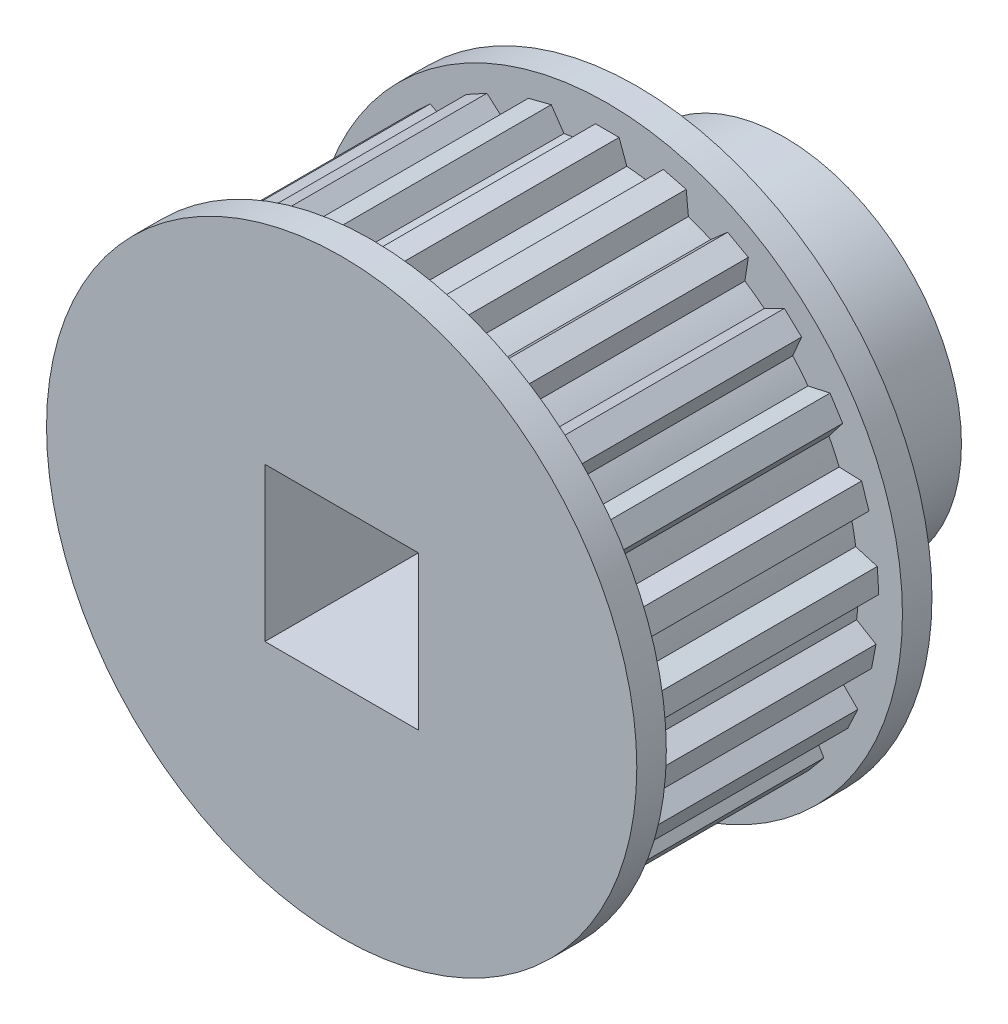
from build123d import *

# Parameters (mm, degrees)
BOSS_EXTRUDE1_DEPTH = 5
SKETCH2_R           = 10
BOSS_EXTRUDE2_DEPTH = 1
SKETCH4_R           = 6
BOSS_EXTRUDE3_DEPTH = 5
CUT_EXTRUDE1_REACH  = 17
SKETCH5_W           = 5.2
SKETCH5_H           = 5.2


with BuildPart() as part:
    # Sketch1 → Boss-Extrude1 (new body, symmetric)
    with BuildSketch(Plane.XY):
        with BuildLine():
            Line((-0.4, 9.191300234), (-0.660980834, 8.474261286))
            ThreePointArc((-0.660980834, 8.474261286), (-1.065332485, 8.432974961), (-1.467248177, 8.372406033))
            Line((-1.467248177, 8.372406033), (-1.898350154, 9.002014591))
            Line((-1.898350154, 9.002014591), (-2.673216683, 8.803062681))
            Line((-2.673216683, 8.803062681), (-2.747677989, 8.043647535))
            ThreePointArc((-2.747677989, 8.043647535), (-3.129058698, 7.90310013), (-3.503284589, 7.744481718))
            Line((-3.503284589, 7.744481718), (-4.077419986, 8.247099263))
            Line((-4.077419986, 8.247099263), (-4.77846533, 7.861696324))
            Line((-4.77846533, 7.861696324), (-4.66172843, 7.107621828))
            ThreePointArc((-4.66172843, 7.107621828), (-4.996174644, 6.876644452), (-5.319196746, 6.629943135))
            Line((-5.319196746, 6.629943135), (-6.000290524, 6.973988359))
            Line((-6.000290524, 6.973988359), (-6.583465426, 6.426350674))
            Line((-6.583465426, 6.426350674), (-6.282865329, 5.724998101))
            ThreePointArc((-6.282865329, 5.724998101), (-6.549362564, 5.418103913), (-6.80088421, 5.098820841))
            Line((-6.80088421, 5.098820841), (-7.546140742, 5.262676117))
            Line((-7.546140742, 5.262676117), (-7.974802178, 4.587213776))
            Line((-7.974802178, 4.587213776), (-7.509226693, 3.982651688))
            ThreePointArc((-7.509226693, 3.982651688), (-7.691029946, 3.619123978), (-7.855247106, 3.247320882))
            Line((-7.855247106, 3.247320882), (-8.617839183, 3.220690579))
            Line((-8.617839183, 3.220690579), (-8.865052779, 2.459845366))
            Line((-8.865052779, 2.459845366), (-8.263755727, 1.990060623))
            ThreePointArc((-8.263755727, 1.990060623), (-8.349441631, 1.592741174), (-8.416035937, 1.191779808))
            Line((-8.416035937, 1.191779808), (-9.148047095, 0.976337208))
            Line((-9.148047095, 0.976337208), (-9.198279511, 0.177915826))
            Line((-9.198279511, 0.177915826), (-8.499042597, -0.127573271))
            ThreePointArc((-8.499042597, -0.127573271), (-8.483227192, -0.533719416), (-8.448014278, -0.938645173))
            Line((-8.448014278, -0.938645173), (-9.103449564, -1.32936302))
            Line((-9.103449564, -1.32936302), (-8.953544512, -2.115192821))
            Line((-8.953544512, -2.115192821), (-8.200303363, -2.237191266))
            ThreePointArc((-8.200303363, -2.237191266), (-8.083980389, -2.626644452), (-7.949172812, -3.010091627))
            Line((-7.949172812, -3.010091627), (-8.486848816, -3.551534481))
            Line((-8.486848816, -3.551534481), (-8.146225383, -4.275396123))
            Line((-8.146225383, -4.275396123), (-7.38630891, -4.206238307))
            ThreePointArc((-7.38630891, -4.206238307), (-7.176787367, -4.554527757), (-6.950855584, -4.892402953))
            Line((-6.950855584, -4.892402953), (-7.336988145, -5.550549969))
            Line((-7.336988145, -5.550549969), (-6.827048953, -6.166960564))
            Line((-6.827048953, -6.166960564), (-6.108205503, -5.910991925))
            ThreePointArc((-6.108205503, -5.910991925), (-5.8186504, -6.196233333), (-5.515790536, -6.467306608))
            Line((-5.515790536, -6.467306608), (-5.726117525, -7.200803989))
            Line((-5.726117525, -7.200803989), (-5.078903929, -7.671032191))
            Line((-5.078903929, -7.671032191), (-4.44630108, -7.244336181))
            ThreePointArc((-4.44630108, -7.244336181), (-4.09490623, -7.44860678), (-3.734148082, -7.635845605))
            Line((-3.734148082, -7.635845605), (-3.755453882, -8.398605012))
            Line((-3.755453882, -8.398605012), (-3.011632693, -8.693104654))
            Line((-3.011632693, -8.693104654), (-2.505019208, -8.122492153))
            ThreePointArc((-2.505019208, -8.122492153), (-2.113864041, -8.23295687), (-1.717875372, -8.324596339))
            Line((-1.717875372, -8.324596339), (-1.54882126, -9.068690793))
            Line((-1.54882126, -9.068690793), (-0.755129499, -9.16895738))
            Line((-0.755129499, -9.16895738), (-0.406337766, -8.49028207))
            ThreePointArc((-0.406337766, -8.49028207), (0, -8.5), (0.406337766, -8.49028207))
            Line((0.406337766, -8.49028207), (0.755129499, -9.16895738))
            Line((0.755129499, -9.16895738), (1.54882126, -9.068690793))
            Line((1.54882126, -9.068690793), (1.717875372, -8.324596339))
            ThreePointArc((1.717875372, -8.324596339), (2.113864041, -8.23295687), (2.505019208, -8.122492153))
            Line((2.505019208, -8.122492153), (3.011632693, -8.693104654))
            Line((3.011632693, -8.693104654), (3.755453882, -8.398605012))
            Line((3.755453882, -8.398605012), (3.734148082, -7.635845605))
            ThreePointArc((3.734148082, -7.635845605), (4.09490623, -7.44860678), (4.44630108, -7.244336181))
            Line((4.44630108, -7.244336181), (5.078903929, -7.671032191))
            Line((5.078903929, -7.671032191), (5.726117525, -7.200803989))
            Line((5.726117525, -7.200803989), (5.515790536, -6.467306608))
            ThreePointArc((5.515790536, -6.467306608), (5.8186504, -6.196233333), (6.108205503, -5.910991925))
            Line((6.108205503, -5.910991925), (6.827048953, -6.166960564))
            Line((6.827048953, -6.166960564), (7.336988145, -5.550549969))
            Line((7.336988145, -5.550549969), (6.950855584, -4.892402953))
            ThreePointArc((6.950855584, -4.892402953), (7.176787367, -4.554527757), (7.38630891, -4.206238307))
            Line((7.38630891, -4.206238307), (8.146225383, -4.275396123))
            Line((8.146225383, -4.275396123), (8.486848816, -3.551534481))
            Line((8.486848816, -3.551534481), (7.949172812, -3.010091627))
            ThreePointArc((7.949172812, -3.010091627), (8.083980389, -2.626644452), (8.200303363, -2.237191266))
            Line((8.200303363, -2.237191266), (8.953544512, -2.115192821))
            Line((8.953544512, -2.115192821), (9.103449564, -1.32936302))
            Line((9.103449564, -1.32936302), (8.448014278, -0.938645173))
            ThreePointArc((8.448014278, -0.938645173), (8.483227192, -0.533719416), (8.499042597, -0.127573271))
            Line((8.499042597, -0.127573271), (9.198279511, 0.177915826))
            Line((9.198279511, 0.177915826), (9.148047095, 0.976337208))
            Line((9.148047095, 0.976337208), (8.416035937, 1.191779808))
            ThreePointArc((8.416035937, 1.191779808), (8.349441631, 1.592741174), (8.263755727, 1.990060623))
            Line((8.263755727, 1.990060623), (8.865052779, 2.459845366))
            Line((8.865052779, 2.459845366), (8.617839183, 3.220690579))
            Line((8.617839183, 3.220690579), (7.855247106, 3.247320882))
            ThreePointArc((7.855247106, 3.247320882), (7.691029946, 3.619123978), (7.509226693, 3.982651688))
            Line((7.509226693, 3.982651688), (7.974802178, 4.587213776))
            Line((7.974802178, 4.587213776), (7.546140742, 5.262676117))
            Line((7.546140742, 5.262676117), (6.80088421, 5.098820841))
            ThreePointArc((6.80088421, 5.098820841), (6.549362564, 5.418103913), (6.282865329, 5.724998101))
            Line((6.282865329, 5.724998101), (6.583465426, 6.426350674))
            Line((6.583465426, 6.426350674), (6.000290524, 6.973988359))
            Line((6.000290524, 6.973988359), (5.319196746, 6.629943135))
            ThreePointArc((5.319196746, 6.629943135), (4.996174644, 6.876644452), (4.66172843, 7.107621828))
            Line((4.66172843, 7.107621828), (4.77846533, 7.861696324))
            Line((4.77846533, 7.861696324), (4.077419986, 8.247099263))
            Line((4.077419986, 8.247099263), (3.503284589, 7.744481718))
            ThreePointArc((3.503284589, 7.744481718), (3.129058698, 7.90310013), (2.747677989, 8.043647535))
            Line((2.747677989, 8.043647535), (2.673216683, 8.803062681))
            Line((2.673216683, 8.803062681), (1.898350154, 9.002014591))
            Line((1.898350154, 9.002014591), (1.467248177, 8.372406033))
            ThreePointArc((1.467248177, 8.372406033), (1.065332485, 8.432974961), (0.660980834, 8.474261286))
            Line((0.660980834, 8.474261286), (0.4, 9.191300234))
            Line((0.4, 9.191300234), (-0.4, 9.191300234))
        make_face()
    extrude(amount=BOSS_EXTRUDE1_DEPTH, both=True)

    # Sketch2 → Boss-Extrude2 (add)
    with BuildSketch(Plane.XY.offset(5)):
        Circle(SKETCH2_R)
    boss_extrude2 = extrude(amount=-BOSS_EXTRUDE2_DEPTH)

    # Mirror1: Boss-Extrude2 across plane
    add(boss_extrude2.mirror(Plane.XY))

    # Sketch4 → Boss-Extrude3 (add)
    with BuildSketch(Plane(origin=(0, 0, -5), x_dir=(-1, 0, 0), z_dir=(0, 0, -1))):
        Circle(SKETCH4_R)
    extrude(amount=BOSS_EXTRUDE3_DEPTH)

    # Sketch5 → Cut-Extrude1 (cut, up to next)
    with BuildSketch(Plane.XY.offset(5), mode=Mode.PRIVATE) as cut_extrude1_sk1:
        Rectangle(SKETCH5_W, SKETCH5_H)
    cut_extrude1_tool1 = extrude(cut_extrude1_sk1.sketch, amount=-CUT_EXTRUDE1_REACH, mode=Mode.PRIVATE) & part.part
    add(cut_extrude1_tool1.solids().sort_by_distance((0, 0, 5))[0], mode=Mode.SUBTRACT)


solid = part.part
